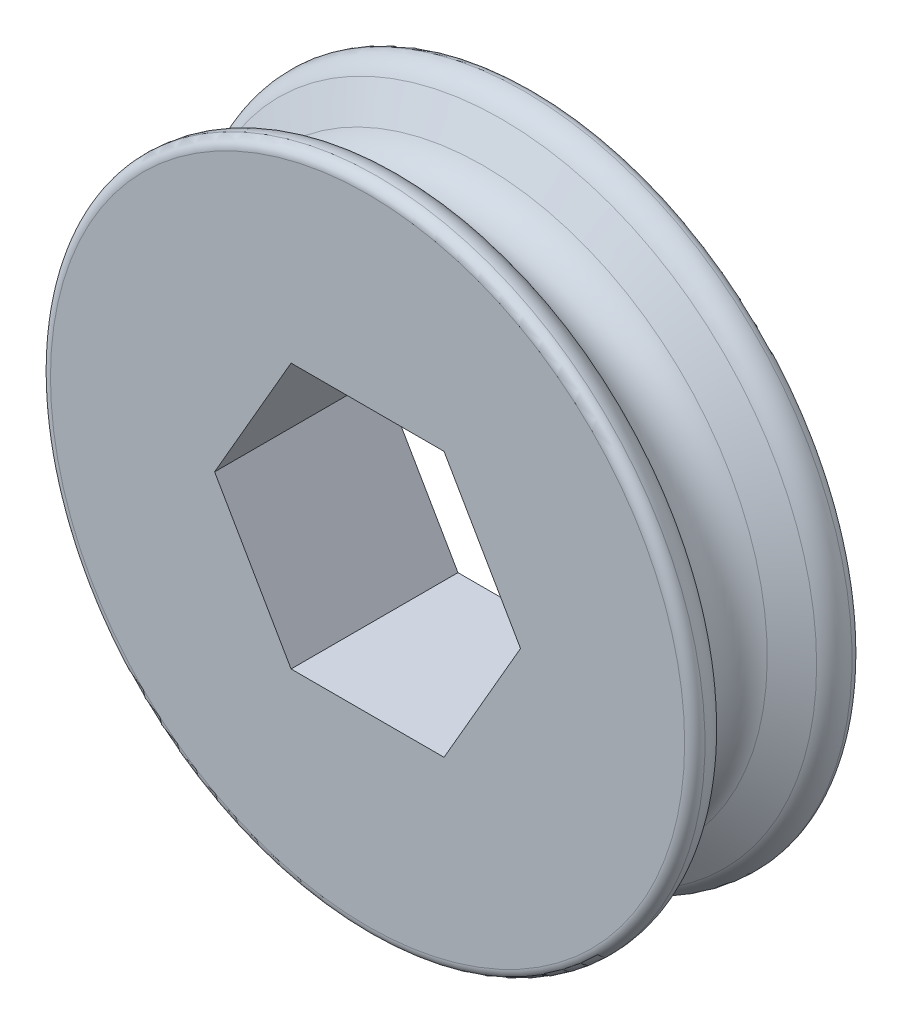
from build123d import *

# Parameters (mm, degrees)
CUT_EXTRUDE2_DEPTH = 9.0000094


with BuildPart() as part:
    # Sketch1 → Revolve1 (revolve)
    with BuildSketch(Plane(origin=(0, 0, 0), x_dir=(0, 0, -1), z_dir=(1, 0, 0))):
        with BuildLine():
            Line((4.0000047, 0), (-4.0000047, 0))
            Line((-4.0000047, 0), (-4.0000047, 15.200621907))
            ThreePointArc((-4.0000047, 15.200621907), (-3.862299847, 15.545211447), (-3.525035946, 15.699994))
            ThreePointArc((-3.525035946, 15.699994), (-2.891173009, 15.55542644), (-2.425734949, 15.101499778))
            Line((-2.425734949, 15.101499778), (-1.558842609, 13.5999982))
            ThreePointArc((-1.558842609, 13.5999982), (0, 12.7), (1.558842609, 13.5999982))
            Line((1.558842609, 13.5999982), (2.425734949, 15.101499778))
            ThreePointArc((2.425734949, 15.101499778), (2.891173009, 15.55542644), (3.525035946, 15.699994))
            ThreePointArc((3.525035946, 15.699994), (3.862299847, 15.545211447), (4.0000047, 15.200621907))
            Line((4.0000047, 15.200621907), (4.0000047, 0))
        make_face()
    revolve(axis=Axis((0, 0, -4.0000047), (0, 0, 1)))

    # Sketch2 → Cut-Extrude2 (cut, through all)
    with BuildSketch(Plane.XY.offset(4.0000047)):
        Polygon((7.332348419, 0), (3.666174209, 6.35), (-3.666174209, 6.35), (-7.332348419, 0), (-3.666174209, -6.35), (3.666174209, -6.35), align=None)
    extrude(amount=-CUT_EXTRUDE2_DEPTH, mode=Mode.SUBTRACT)


solid = part.part
